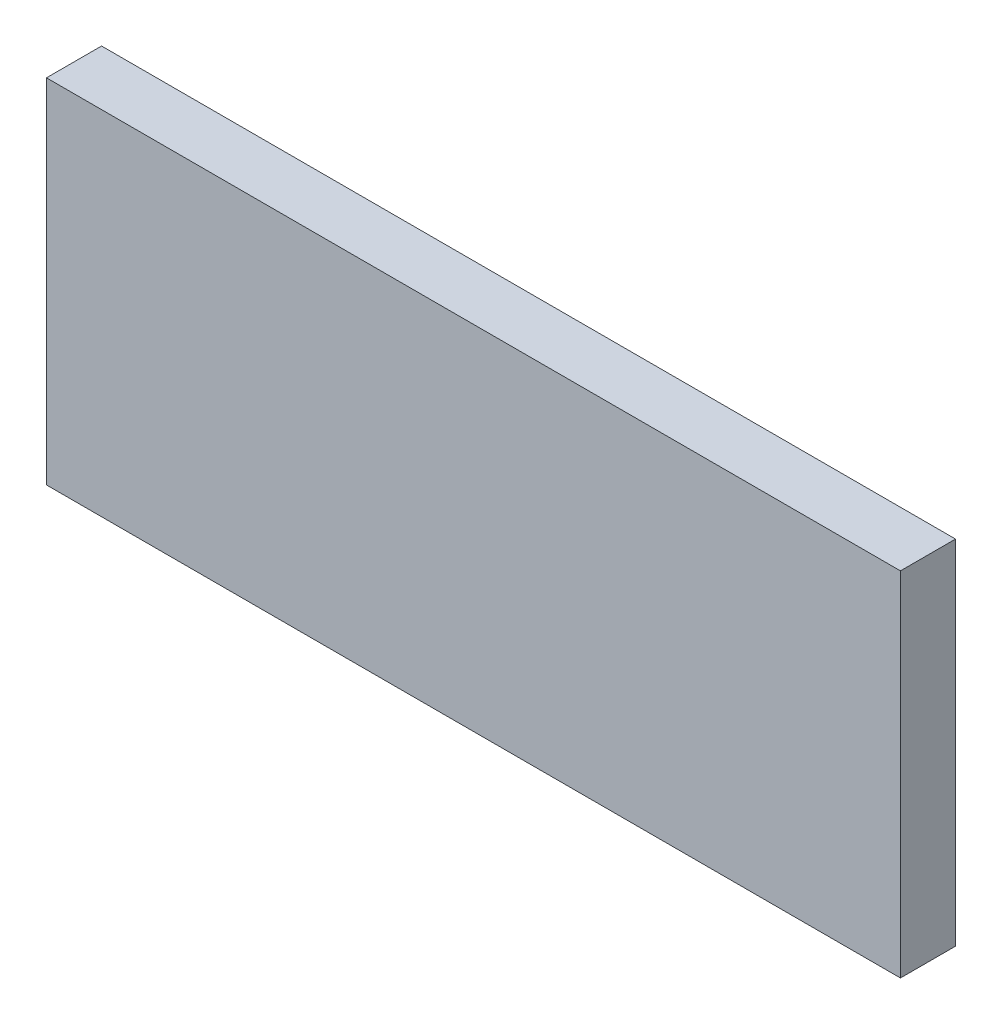
from build123d import *

# Parameters (mm, degrees)
ESQUISSE1_W        = 155
ESQUISSE1_H        = 64
BOSS_EXTRU_1_DEPTH = 10


with BuildPart() as part:
    # Esquisse1 → Boss.-Extru.1 (new body)
    with BuildSketch(Plane.XY):
        with Locations((-77.5, 32)):
            Rectangle(ESQUISSE1_W, ESQUISSE1_H)
    extrude(amount=BOSS_EXTRU_1_DEPTH)


solid = part.part
